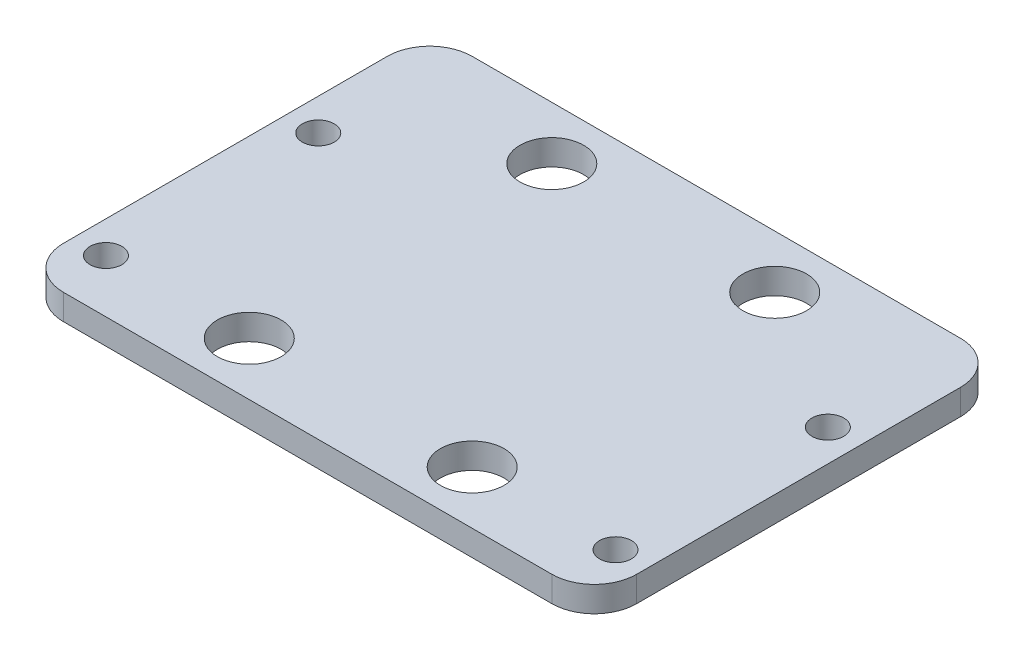
from build123d import *

# Parameters (mm, degrees)
SKETCH_1_W      = 54
SKETCH_1_H      = 38.5
SKETCH_1_R      = 1.5
SKETCH_1_R_2    = 3
EXTRUDE_1_DEPTH = 2.4
FILLET_1_R      = 4


with BuildPart() as part:
    # 草圖1 → 填料-伸長1 (new body)
    with BuildSketch(Plane(origin=(0, 0, 0), x_dir=(1, 0, 0), z_dir=(0, 1, 0))):
        with Locations((0, 14.25)):
            Rectangle(SKETCH_1_W, SKETCH_1_H)
        with Locations((-24, 0)):
            Circle(SKETCH_1_R, mode=Mode.SUBTRACT)
        with Locations((24, 0)):
            Circle(SKETCH_1_R, mode=Mode.SUBTRACT)
        with Locations((-10.5, 28.5)):
            Circle(SKETCH_1_R_2, mode=Mode.SUBTRACT)
        with Locations((10.5, 28.5)):
            Circle(SKETCH_1_R_2, mode=Mode.SUBTRACT)
        with Locations((-10.5, 0)):
            Circle(SKETCH_1_R_2, mode=Mode.SUBTRACT)
        with Locations((10.5, 0)):
            Circle(SKETCH_1_R_2, mode=Mode.SUBTRACT)
        with Locations((24, 20)):
            Circle(SKETCH_1_R, mode=Mode.SUBTRACT)
        with Locations((-24, 20)):
            Circle(SKETCH_1_R, mode=Mode.SUBTRACT)
    extrude(amount=EXTRUDE_1_DEPTH)

    # 圓角1
    fillet_1_edges = [part.edges().sort_by_distance(p)[0] for p in [
        (27, 1.2, 5),
        (-27, 1.2, 5),
        (-27, 1.2, -33.5),
        (27, 1.2, -33.5),
    ]]
    fillet(fillet_1_edges, radius=FILLET_1_R)


solid = part.part
